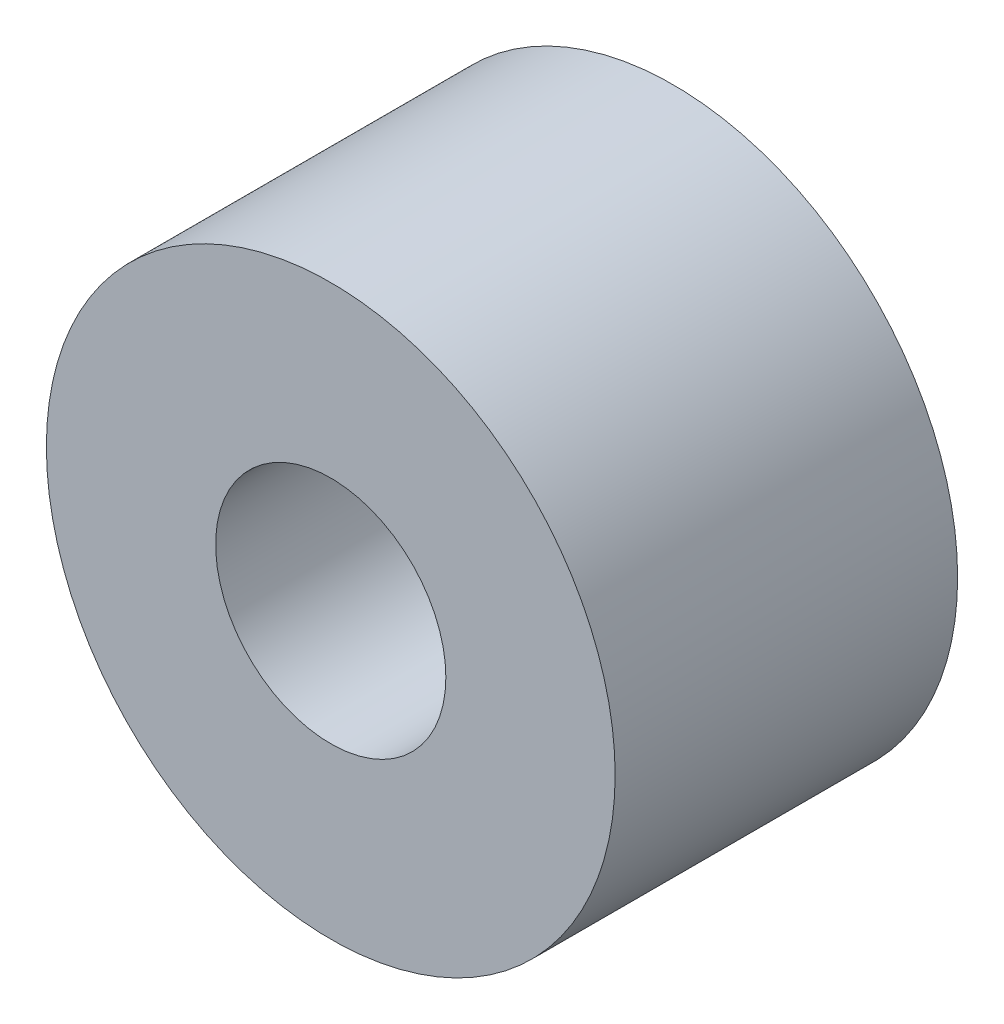
from build123d import *

# Parameters (mm, degrees)
SKETCH1_W           = 3.125
SKETCH1_H           = 3.75
SKETCH2_R           = 5.25
SKETCH2_R_2         = 2.125
BOSS_EXTRUDE1_DEPTH = 3.0725
SKETCH3_R           = 5.25
SKETCH3_R_2         = 3
CUT_EXTRUDE1_DEPTH  = 0.5


with BuildPart() as part:
    # Sketch1 → Revolve1 (revolve)
    with BuildSketch(Plane(origin=(0, 0, 0), x_dir=(1, 0, 0), z_dir=(0, 1, 0))):
        with Locations((3.6875, -1.875)):
            Rectangle(SKETCH1_W, SKETCH1_H)
    revolve(axis=Axis((0, 0, 0), (0, 0, 1)))

    # Sketch2 → Boss-Extrude1 (add)
    with BuildSketch(Plane.XY.offset(3.75)):
        Circle(SKETCH2_R)
        Circle(SKETCH2_R_2, mode=Mode.SUBTRACT)
    extrude(amount=BOSS_EXTRUDE1_DEPTH)

    # Sketch3 → Cut-Extrude1 (cut)
    with BuildSketch(Plane(origin=(0, 0, 0), x_dir=(-1, 0, 0), z_dir=(0, 0, -1))):
        Circle(SKETCH3_R)
        Circle(SKETCH3_R_2, mode=Mode.SUBTRACT)
    extrude(amount=-CUT_EXTRUDE1_DEPTH, mode=Mode.SUBTRACT)


solid = part.part
